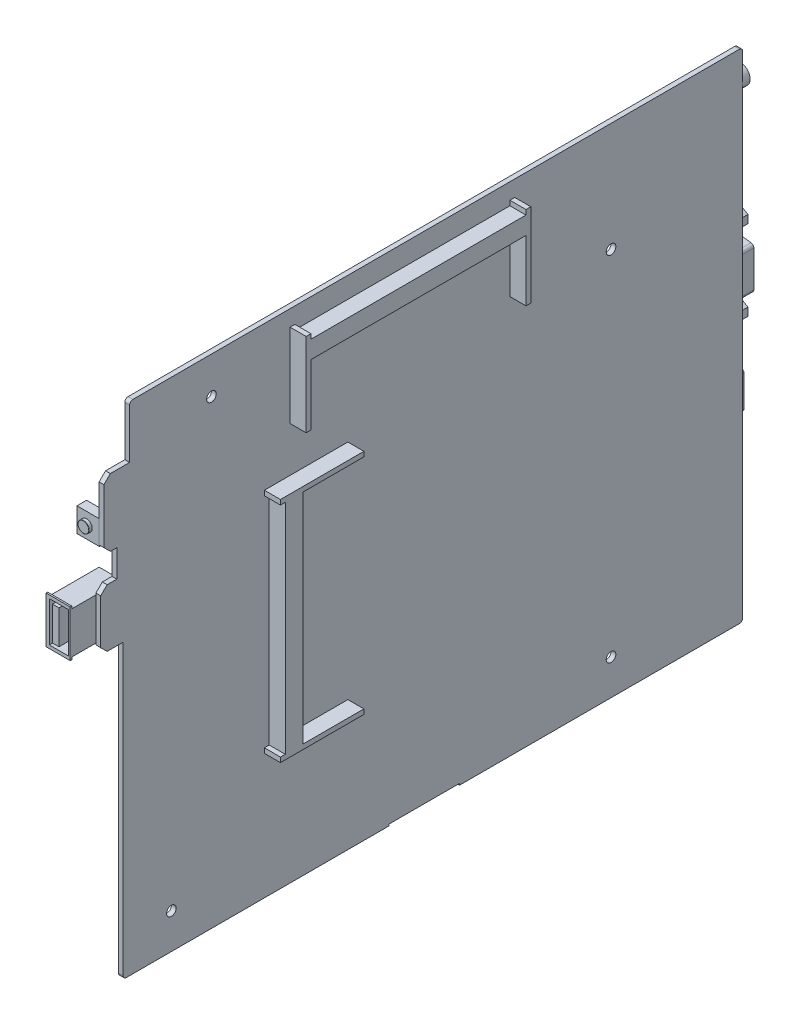
from build123d import *

# Parameters (mm, degrees)
EXTRUDE_1_DEPTH              = 1.5
CHAMFER_1_SIZE               = 2
FILLET_1_R                   = 1
EXTRUDE_2_DEPTH              = 5
SKETCH_4_W                   = 25
SKETCH_4_H                   = 8.5
EXTRUDE_3_DEPTH              = 11
SKETCH_5_W                   = 11.5
SKETCH_5_H                   = 2
SKETCH_5_W_2                 = 9
SKETCH_5_W_3                 = 0.5
CUT_EXTRUDE_1_DEPTH          = 8
SKETCH_6_W                   = 22
SKETCH_6_H                   = 1.5
CUT_EXTRUDE_2_DEPTH          = 18.5
EXTRUDE_4_DEPTH              = 7.5
SKETCH_8_W                   = 15.5
SKETCH_8_H                   = 13
CUT_EXTRUDE_3_DEPTH          = 0.5
SKETCH_9_W                   = 6
SKETCH_9_H                   = 12.5
SKETCH_9_W_2                 = 2
SKETCH_9_H_2                 = 10.5
CUT_EXTRUDE_4_DEPTH          = 13
SKETCH_10_W                  = 3
SKETCH_10_H                  = 7.5
EXTRUDE_5_DEPTH              = 7
SKETCH_11_R                  = 1.75
EXTRUDE_6_DEPTH              = 1
FILLET_2_R                   = 0.1
SKETCH_12_W                  = 15
SKETCH_12_H                  = 10
EXTRUDE_7_DEPTH              = 4.5
SKETCH_13_R                  = 3
SKETCH_13_R_2                = 1.5
EXTRUDE_8_DEPTH              = 2.5
SKETCH_14_W                  = 2.5
SKETCH_14_H                  = 7
EXTRUDE_9_DEPTH              = 3.5
SKETCH_15_W                  = 1.5
SKETCH_15_H                  = 3
EXTRUDE_10_DEPTH             = 1
SKETCH_16_W                  = 3
SKETCH_16_H                  = 9
EXTRUDE_11_DEPTH             = 2.5
SKETCH_17_W                  = 0.5
SKETCH_17_H                  = 1.5
EXTRUDE_12_DEPTH             = 2
SKETCH_18_W                  = 4.5
SKETCH_18_H                  = 31
EXTRUDE_13_DEPTH             = 12
EXTRUDE_14_DEPTH             = 6
EXTRUDE_15_DEPTH             = 6
HOLE_WIZARD_M3_1_D           = 2.5
HOLE_WIZARD_M3_1_DEPTH       = 7.5
HOLE_WIZARD_M3_1_CSINK_D     = 3
HOLE_WIZARD_M3_1_CSINK_ANGLE = 90
HOLE_WIZARD_M3_1_TIP         = 0.751075774
SKETCH_23_R                  = 0.5
CUT_EXTRUDE_5_DEPTH          = 5
PATTERN_LINEAR_1_COUNT       = 5
PATTERN_LINEAR_1_PITCH       = 2.5
SKETCH_24_W                  = 12
SKETCH_24_H                  = 15
EXTRUDE_16_DEPTH             = 6
SKETCH_25_W                  = 1
SKETCH_25_H                  = 10
CUT_EXTRUDE_6_DEPTH          = 10
SKETCH_26_W                  = 1
SKETCH_26_H                  = 10
CUT_EXTRUDE_7_DEPTH          = 2
SKETCH_27_W                  = 28.5
SKETCH_27_H                  = 17.5
EXTRUDE_17_DEPTH             = 26
CUT_EXTRUDE_8_DEPTH          = 10
SKETCH_29_W                  = 1.5
SKETCH_29_H                  = 4
CUT_EXTRUDE_9_DEPTH          = 3
EXTRUDE_18_DEPTH             = 15
SKETCH_31_W                  = 16.5
SKETCH_31_H                  = 13
CUT_EXTRUDE_10_DEPTH         = 0.5
SKETCH_32_W                  = 5
SKETCH_32_H                  = 12
SKETCH_32_W_2                = 1.5
SKETCH_32_H_2                = 9
CUT_EXTRUDE_11_DEPTH         = 10
SKETCH_33_W                  = 13
SKETCH_33_H                  = 10
EXTRUDE_19_DEPTH             = 10
SKETCH_34_R                  = 3
SKETCH_34_R_2                = 0.75
CUT_EXTRUDE_12_DEPTH         = 10
SKETCH_35_R                  = 0.75
CUT_EXTRUDE_13_DEPTH         = 2
FILLET_3_R                   = 0.75
SKETCH_36_R                  = 1.5
CUT_EXTRUDE_14_DEPTH         = 10


with BuildPart() as part:
    # 草图1 → 凸台-拉伸1 (new body)
    with BuildSketch(Plane(origin=(0, 0, 0), x_dir=(0, 0, -1), z_dir=(1, 0, 0))):
        Polygon((-94.5, 77.5), (96.5, 77.5), (96.5, -77.5), (-96.5, -77.5), (-96.5, 13.5), (-103.5, 13.5), (-103.5, 31.5), (-98.5, 31.5), (-98.5, 40), (-102.5, 40), (-102.5, 61), (-94.5, 61), align=None)
    extrude(amount=-EXTRUDE_1_DEPTH)

    # 倒角1
    chamfer_1_edges = [part.edges().sort_by_distance(p)[0] for p in [
        (-0.75, 13.5, 103.5),
        (-0.75, 31.5, 103.5),
        (-0.75, 40, 102.5),
        (-0.75, 61, 102.5),
    ]]
    chamfer(chamfer_1_edges, length=CHAMFER_1_SIZE)

    # 圆角1
    fillet_1_edges = [part.edges().sort_by_distance(p)[0] for p in [
        (-0.75, -77.5, -96.5),
        (-0.75, -77.5, 96.5),
        (-0.75, 77.5, 94.5),
        (-0.75, 77.5, -96.5),
    ]]
    fillet(fillet_1_edges, radius=FILLET_1_R)

    # 草图3 → 凸台-拉伸2 (add)
    with BuildSketch(Plane(origin=(0, 0, 0), x_dir=(0, 0, -1), z_dir=(1, 0, 0))):
        Polygon((-44.5, 46.5), (-43, 46.5), (-43, 65.5), (24, 65.5), (24, 46.5), (25.5, 46.5), (25.5, 72.5), (24, 72.5), (24, 71), (-43, 71), (-43, 72.5), (-44.5, 72.5), align=None)
        Polygon((-52.5, 32.5), (-26.5, 32.5), (-26.5, 31), (-45.5, 31), (-45.5, -37), (-26.5, -37), (-26.5, -38.5), (-52.5, -38.5), (-52.5, -37), (-51, -37), (-51, 31), (-52.5, 31), align=None)
    extrude(amount=EXTRUDE_2_DEPTH)

    # 草图4 → 凸台-拉伸3 (add)
    with BuildSketch(Plane.ZY.offset(1.5)):
        with Locations((2.75, -74.25)):
            Rectangle(SKETCH_4_W, SKETCH_4_H)
    extrude(amount=EXTRUDE_3_DEPTH)

    # 草图5 → 切除-拉伸1 (cut)
    with BuildSketch(Plane.ZY.offset(12.5)):
        with Locations((-2.5, -73.5)):
            Rectangle(SKETCH_5_W, SKETCH_5_H)
        with Locations((9.25, -73.5)):
            Rectangle(SKETCH_5_W_2, SKETCH_5_H)
        with Locations((-9.5, -73.5)):
            Rectangle(SKETCH_5_W_3, SKETCH_5_H)
        with Locations((15, -73.5)):
            Rectangle(SKETCH_5_W_3, SKETCH_5_H)
    extrude(amount=-CUT_EXTRUDE_1_DEPTH, mode=Mode.SUBTRACT)

    # 草图6 → 切除-拉伸2 (cut, through all)
    with BuildSketch(Plane.ZY.offset(12.5)):
        with Locations((2.75, -77.75)):
            Rectangle(SKETCH_6_W, SKETCH_6_H)
    extrude(amount=-CUT_EXTRUDE_2_DEPTH, mode=Mode.SUBTRACT)

    # 草图7 → 凸台-拉伸4 (add)
    with BuildSketch(Plane.ZY.offset(1.5)):
        Polygon((111, 29.75), (111.5, 29.75), (111.5, 15.25), (111, 15.25), (111, 16), (95.5, 16), (95.5, 29), (111, 29), align=None)
    extrude(amount=EXTRUDE_4_DEPTH)

    # 草图8 → 切除-拉伸3 (cut)
    with BuildSketch(Plane.ZY.offset(9)):
        with Locations((103.25, 22.5)):
            Rectangle(SKETCH_8_W, SKETCH_8_H)
    extrude(amount=-CUT_EXTRUDE_3_DEPTH, mode=Mode.SUBTRACT)

    # 草图9 → 切除-拉伸4 (cut)
    with BuildSketch(Plane.XY.offset(111.5)):
        with Locations((-5, 22.5)):
            Rectangle(SKETCH_9_W, SKETCH_9_H)
        with Locations((-6, 22.5)):
            Rectangle(SKETCH_9_W_2, SKETCH_9_H_2, mode=Mode.SUBTRACT)
    extrude(amount=-CUT_EXTRUDE_4_DEPTH, mode=Mode.SUBTRACT)

    # 草图10 → 凸台-拉伸5 (add)
    with BuildSketch(Plane.ZY.offset(1.5)):
        with Locations((100.9, 45.25)):
            Rectangle(SKETCH_10_W, SKETCH_10_H)
    extrude(amount=EXTRUDE_5_DEPTH)

    # 草图11 → 凸台-拉伸6 (add)
    with BuildSketch(Plane.XY.offset(102.4)):
        with Locations((-5.5, 45.25)):
            Circle(SKETCH_11_R)
    extrude(amount=EXTRUDE_6_DEPTH)

    # 圆角2
    fillet_2_edges = [part.edges().sort_by_distance(p)[0] for p in [
        (-7.25, 45.25, 103.4),
    ]]
    fillet(fillet_2_edges, radius=FILLET_2_R)

    # 草图12 → 凸台-拉伸7 (add)
    with BuildSketch(Plane.ZY.offset(1.5)):
        with Locations((-89.1, 67.5)):
            Rectangle(SKETCH_12_W, SKETCH_12_H)
    extrude(amount=EXTRUDE_7_DEPTH)

    # 草图13 → 凸台-拉伸8 (add)
    with BuildSketch(Plane(origin=(0, 0, -96.6), x_dir=(-1, 0, 0), z_dir=(0, 0, -1))):
        with Locations((3.25, 67.5)):
            Circle(SKETCH_13_R)
        with Locations((3.25, 67.5)):
            Circle(SKETCH_13_R_2, mode=Mode.SUBTRACT)
    extrude(amount=EXTRUDE_8_DEPTH)

    # 草图14 → 凸台-拉伸9 (add)
    with BuildSketch(Plane.ZY.offset(1.5)):
        with Locations((-95.15, 57)):
            Rectangle(SKETCH_14_W, SKETCH_14_H)
        with Locations((-95.15, 47)):
            Rectangle(SKETCH_14_W, SKETCH_14_H)
    extrude(amount=EXTRUDE_9_DEPTH)

    # 草图15 → 凸台-拉伸10 (add)
    with BuildSketch(Plane(origin=(0, 0, -96.4), x_dir=(-1, 0, 0), z_dir=(0, 0, -1))):
        with Locations((3.25, 57)):
            Rectangle(SKETCH_15_W, SKETCH_15_H)
        with Locations((3.25, 47)):
            Rectangle(SKETCH_15_W, SKETCH_15_H)
    extrude(amount=EXTRUDE_10_DEPTH)

    # 草图16 → 凸台-拉伸11 (add)
    with BuildSketch(Plane.ZY.offset(1.5)):
        with Locations((-94, 37)):
            Rectangle(SKETCH_16_W, SKETCH_16_H)
    extrude(amount=EXTRUDE_11_DEPTH)

    # 草图17 → 凸台-拉伸12 (add)
    with BuildSketch(Plane(origin=(0, 0, -95.5), x_dir=(-1, 0, 0), z_dir=(0, 0, -1))):
        with Locations((2.75, 39.25)):
            Rectangle(SKETCH_17_W, SKETCH_17_H)
    extrude(amount=EXTRUDE_12_DEPTH)

    # 草图18 → 凸台-拉伸13 (add)
    with BuildSketch(Plane.ZY.offset(1.5)):
        with Locations((-95.25, 12.5)):
            Rectangle(SKETCH_18_W, SKETCH_18_H)
    extrude(amount=EXTRUDE_13_DEPTH)

    # 草图19 → 凸台-拉伸14 (add)
    with BuildSketch(Plane(origin=(0, 0, -97.5), x_dir=(-1, 0, 0), z_dir=(0, 0, -1))):
        Polygon((7.5, 22.5), (9.665063509, 23.75), (9.665063509, 26.25), (7.5, 27.5), (5.334936491, 26.25), (5.334936491, 23.75), align=None)
        Polygon((7.5, -2.5), (9.665063509, -1.25), (9.665063509, 1.25), (7.5, 2.5), (5.334936491, 1.25), (5.334936491, -1.25), align=None)
    extrude(amount=EXTRUDE_14_DEPTH)

    # 草图20 → 凸台-拉伸15 (add)
    with BuildSketch(Plane(origin=(0, 0, -97.5), x_dir=(-1, 0, 0), z_dir=(0, 0, -1))):
        with BuildLine():
            Line((3.5, 18.117217781), (3.5, 6.882782219))
            ThreePointArc((3.5, 6.882782219), (3.750321824, 6.220979655), (4.375965265, 5.890504342))
            Line((4.375965265, 5.890504342), (10.375965265, 5.140504342))
            ThreePointArc((10.375965265, 5.140504342), (11.161802563, 5.383104043), (11.5, 6.132782219))
            Line((11.5, 6.132782219), (11.5, 18.867217781))
            ThreePointArc((11.5, 18.867217781), (11.161802563, 19.616895957), (10.375965265, 19.859495658))
            Line((10.375965265, 19.859495658), (4.375965265, 19.109495658))
            ThreePointArc((4.375965265, 19.109495658), (3.750321824, 18.779020345), (3.5, 18.117217781))
        make_face()
    extrude(amount=EXTRUDE_15_DEPTH)

    # M3 螺纹孔1
    with Locations(Plane(origin=(0, 0, -103.5), x_dir=(-1, 0, 0), z_dir=(0, 0, -1))):
        with Locations((7.507875104, 25.093526995), (7.507875104, 0)):
            CounterSinkHole(HOLE_WIZARD_M3_1_D / 2, HOLE_WIZARD_M3_1_CSINK_D / 2, depth=HOLE_WIZARD_M3_1_DEPTH, counter_sink_angle=HOLE_WIZARD_M3_1_CSINK_ANGLE)
            with Locations((0, 0, -(HOLE_WIZARD_M3_1_DEPTH + HOLE_WIZARD_M3_1_TIP / 2))):  # 118° drill point
                Cone(0, HOLE_WIZARD_M3_1_D / 2, HOLE_WIZARD_M3_1_TIP, mode=Mode.SUBTRACT)

    # 草图23 → 切除-拉伸5 (cut)
    with BuildSketch(Plane(origin=(0, 0, -103.5), x_dir=(-1, 0, 0), z_dir=(0, 0, -1))):
        with Locations((9.5, 17.5)):
            Circle(SKETCH_23_R)
        with Locations((7.375965265, 16.25)):
            Circle(SKETCH_23_R)
        with Locations((5.5, 17.5)):
            Circle(SKETCH_23_R)
    cut_extrude_5 = extrude(amount=-CUT_EXTRUDE_5_DEPTH, mode=Mode.SUBTRACT)

    # 阵列(线性)1: 切除-拉伸5 ×5
    with Locations(*[(0, -i * PATTERN_LINEAR_1_PITCH, 0) for i in range(1, PATTERN_LINEAR_1_COUNT)]):
        add(cut_extrude_5, mode=Mode.SUBTRACT)

    # 草图24 → 凸台-拉伸16 (add)
    with BuildSketch(Plane.ZY.offset(1.5)):
        with Locations((-92.5, -17)):
            Rectangle(SKETCH_24_W, SKETCH_24_H)
    extrude(amount=EXTRUDE_16_DEPTH)

    # 草图25 → 切除-拉伸6 (cut)
    with BuildSketch(Plane(origin=(0, 0, -98.5), x_dir=(-1, 0, 0), z_dir=(0, 0, -1))):
        Polygon((1.5, -9.5), (3.5, -9.5), (1.5, -12), align=None)
        Polygon((1.5, -22), (3.5, -24.5), (1.5, -24.5), align=None)
        Polygon((7, -10), (3.740312424, -10), (2, -12.17539053), (2, -21.82460947), (3.740312424, -24), (7, -24), align=None)
        with Locations((4.5, -17)):
            Rectangle(SKETCH_25_W, SKETCH_25_H, mode=Mode.SUBTRACT)
    extrude(amount=-CUT_EXTRUDE_6_DEPTH, mode=Mode.SUBTRACT)

    # 草图26 → 切除-拉伸7 (cut)
    with BuildSketch(Plane(origin=(0, 0, -98.5), x_dir=(-1, 0, 0), z_dir=(0, 0, -1))):
        with Locations((4.5, -17)):
            Rectangle(SKETCH_26_W, SKETCH_26_H)
    extrude(amount=-CUT_EXTRUDE_7_DEPTH, mode=Mode.SUBTRACT)

    # 草图27 → 凸台-拉伸17 (add)
    with BuildSketch(Plane.ZY.offset(1.5)):
        with Locations((-83.75, -36.75)):
            Rectangle(SKETCH_27_W, SKETCH_27_H)
    extrude(amount=EXTRUDE_17_DEPTH)

    # 草图28 → 切除-拉伸8 (cut)
    with BuildSketch(Plane(origin=(0, 0, -98), x_dir=(-1, 0, 0), z_dir=(0, 0, -1))):
        Polygon((4.5, -30.75), (11.5, -30.75), (11.5, -42.75), (4.5, -42.75), (4.5, -39.75), (3, -39.75), (3, -33.75), (4.5, -33.75), align=None)
        Polygon((24.5, -39.75), (24.5, -42.75), (17.5, -42.75), (17.5, -30.75), (24.5, -30.75), (24.5, -33.75), (26, -33.75), (26, -39.75), align=None)
    extrude(amount=-CUT_EXTRUDE_8_DEPTH, mode=Mode.SUBTRACT)

    # 草图29 → 切除-拉伸9 (cut)
    with BuildSketch(Plane(origin=(0, 0, -98), x_dir=(-1, 0, 0), z_dir=(0, 0, -1))):
        with Locations((26.75, -36.75)):
            Rectangle(SKETCH_29_W, SKETCH_29_H)
        with Locations((2.25, -36.75)):
            Rectangle(SKETCH_29_W, SKETCH_29_H)
    extrude(amount=-CUT_EXTRUDE_9_DEPTH, mode=Mode.SUBTRACT)

    # 草图30 → 凸台-拉伸18 (add)
    with BuildSketch(Plane.ZY.offset(1.5)):
        Polygon((-97.5, -48), (-97, -48), (-97, -49), (-80.5, -49), (-80.5, -62), (-97, -62), (-97, -63), (-97.5, -63), align=None)
    extrude(amount=EXTRUDE_18_DEPTH)

    # 草图31 → 切除-拉伸10 (cut)
    with BuildSketch(Plane.ZY.offset(16.5)):
        with Locations((-88.75, -55.5)):
            Rectangle(SKETCH_31_W, SKETCH_31_H)
    extrude(amount=-CUT_EXTRUDE_10_DEPTH, mode=Mode.SUBTRACT)

    # 草图32 → 切除-拉伸11 (cut)
    with BuildSketch(Plane(origin=(0, 0, -97.5), x_dir=(-1, 0, 0), z_dir=(0, 0, -1))):
        with Locations((13, -55.5)):
            Rectangle(SKETCH_32_W, SKETCH_32_H)
        with Locations((13.25, -55.5)):
            Rectangle(SKETCH_32_W_2, SKETCH_32_H_2, mode=Mode.SUBTRACT)
        with Locations((5, -55.5)):
            Rectangle(SKETCH_32_W, SKETCH_32_H)
        with Locations((5.25, -55.5)):
            Rectangle(SKETCH_32_W_2, SKETCH_32_H_2, mode=Mode.SUBTRACT)
    extrude(amount=-CUT_EXTRUDE_11_DEPTH, mode=Mode.SUBTRACT)

    # 草图33 → 凸台-拉伸19 (add)
    with BuildSketch(Plane.ZY.offset(1.5)):
        with Locations((-91.5, -71.5)):
            Rectangle(SKETCH_33_W, SKETCH_33_H)
    extrude(amount=EXTRUDE_19_DEPTH)

    # 草图34 → 切除-拉伸12 (cut)
    with BuildSketch(Plane(origin=(0, 0, -98), x_dir=(-1, 0, 0), z_dir=(0, 0, -1))):
        with Locations((6.5, -71.5)):
            Circle(SKETCH_34_R)
        with Locations((6.5, -71.5)):
            Circle(SKETCH_34_R_2, mode=Mode.SUBTRACT)
    extrude(amount=-CUT_EXTRUDE_12_DEPTH, mode=Mode.SUBTRACT)

    # 草图35 → 切除-拉伸13 (cut)
    with BuildSketch(Plane(origin=(0, 0, -98), x_dir=(-1, 0, 0), z_dir=(0, 0, -1))):
        with Locations((6.5, -71.5)):
            Circle(SKETCH_35_R)
    extrude(amount=-CUT_EXTRUDE_13_DEPTH, mode=Mode.SUBTRACT)

    # 圆角3
    fillet_3_edges = [part.edges().sort_by_distance(p)[0] for p in [
        (-5.75, -71.5, -96),
    ]]
    fillet(fillet_3_edges, radius=FILLET_3_R)

    # 草图36 → 切除-拉伸14 (cut)
    with BuildSketch(Plane(origin=(0, 0, 0), x_dir=(0, 0, -1), z_dir=(1, 0, 0))):
        with Locations((-69, 66)):
            Circle(SKETCH_36_R)
        with Locations((-81.5, -66.5)):
            Circle(SKETCH_36_R)
        with Locations((55.5, -66.5)):
            Circle(SKETCH_36_R)
        with Locations((55.5, 43.5)):
            Circle(SKETCH_36_R)
    extrude(amount=-CUT_EXTRUDE_14_DEPTH, mode=Mode.SUBTRACT)


solid = part.part
